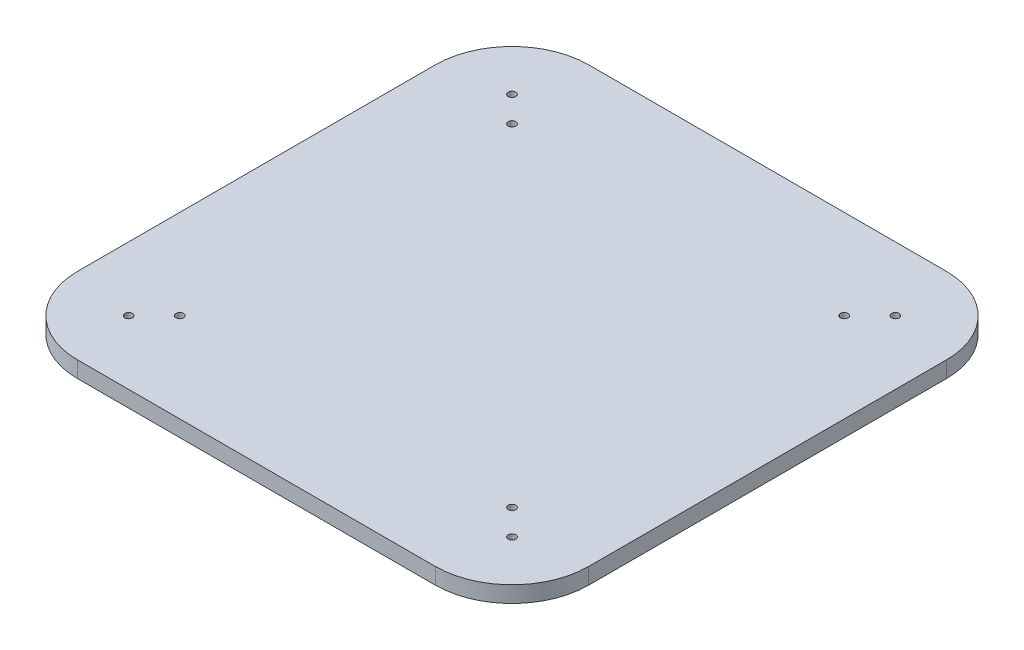
from build123d import *

# Parameters (mm, degrees)
SKETCH1_R           = 1.5
BOSS_EXTRUDE1_DEPTH = 6.35


with BuildPart() as part:
    # Sketch1 → Boss-Extrude1 (new body)
    with BuildSketch(Plane(origin=(0, 0, 0), x_dir=(1, 0, 0), z_dir=(0, 1, 0))):
        with BuildLine():
            Line((-70, -100), (70, -100))
            ThreePointArc((70, -100), (91.213203436, -91.213203436), (100, -70))
            Line((100, -70), (100, 70))
            ThreePointArc((100, 70), (91.213203436, 91.213203436), (70, 100))
            Line((70, 100), (-70, 100))
            ThreePointArc((-70, 100), (-91.213203436, 91.213203436), (-100, 70))
            Line((-100, 70), (-100, -70))
            ThreePointArc((-100, -70), (-91.213203436, -91.213203436), (-70, -100))
        make_face()
        with Locations((75, 75)):
            Circle(SKETCH1_R, mode=Mode.SUBTRACT)
        with Locations((65, 65)):
            Circle(SKETCH1_R, mode=Mode.SUBTRACT)
        with Locations((65, -65)):
            Circle(SKETCH1_R, mode=Mode.SUBTRACT)
        with Locations((75, -75)):
            Circle(SKETCH1_R, mode=Mode.SUBTRACT)
        with Locations((-65, -65)):
            Circle(SKETCH1_R, mode=Mode.SUBTRACT)
        with Locations((-75, -75)):
            Circle(SKETCH1_R, mode=Mode.SUBTRACT)
        with Locations((-65, 65)):
            Circle(SKETCH1_R, mode=Mode.SUBTRACT)
        with Locations((-75, 75)):
            Circle(SKETCH1_R, mode=Mode.SUBTRACT)
    extrude(amount=BOSS_EXTRUDE1_DEPTH)


solid = part.part
